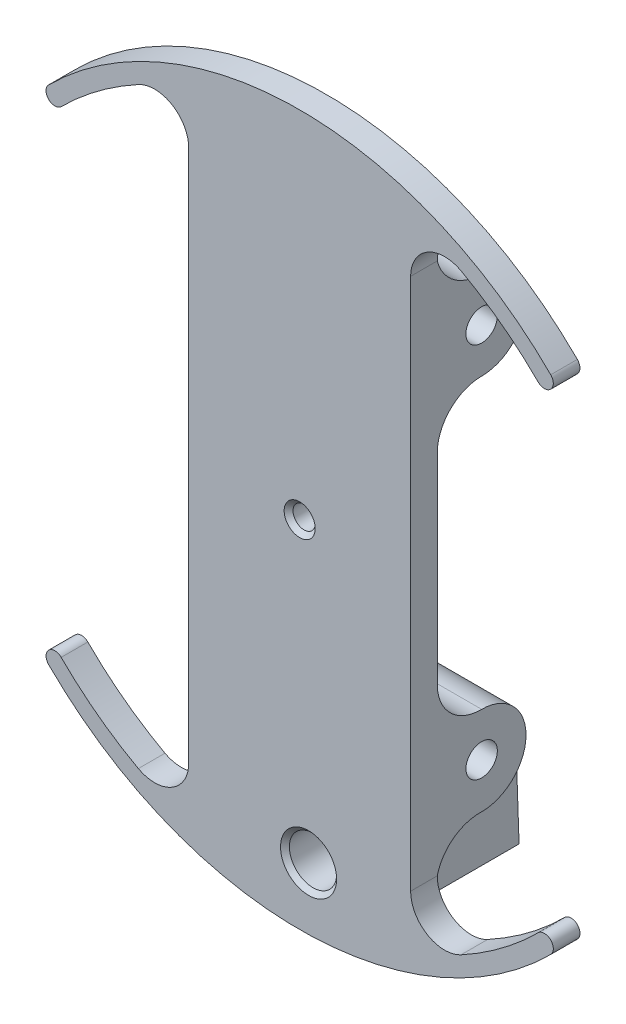
from build123d import *

# Parameters (mm, degrees)
MAIN_BODY_DEPTH                 = 3.81
BOSSES_FOR_SCREWS_DEPTH         = 31.75
F_8_CLEARANCE_HOLE_FOR_SCREWS_D = 4.4958
SWITCH_HOLDER_BODY_REACH        = 65.711
SKETCH19_R                      = 3.3782
F_1_4_QR_PIN_HOLE_D             = 6.7564
F_1_4_QR_PIN_HOLE_CSINK_D       = 8.0264
F_1_4_QR_PIN_HOLE_CSINK_ANGLE   = 90
SKETCH25_R                      = 1.862
PLUNGER_HOLE_DEPTH              = 2.54
SKETCH33_W                      = 6.4
SKETCH33_H                      = 6.4
SWITCH_BODY_CLEARANCE_DEPTH     = 0.65024
F_2_CLEARANCE_HOLE1_D           = 2.4384
F_2_CLEARANCE_HOLE1_DEPTH       = 3.175
TAP_DRILL_FOR_2_56_TAP1_D       = 1.778
TAP_DRILL_FOR_2_56_TAP1_DEPTH   = 12.7


with BuildPart() as part:
    # Sketch3 → Main Body (new body)
    with BuildSketch(Plane.XY):
        with BuildLine():
            Line((-15.875, -38.1), (-15.875, 38.1))
            ThreePointArc((-15.875, 38.1), (-18.260491841, 42.291797068), (-23.082694008, 42.38179842))
            ThreePointArc((-23.082694008, 42.38179842), (-28.900226452, 38.649767283), (-34.12497326, 34.12497326))
            ThreePointArc((-34.12497326, 34.12497326), (-35.921024484, 34.12497326), (-35.921024484, 35.921024484))
            ThreePointArc((-35.921024484, 35.921024484), (0, 50.8), (35.921024484, 35.921024484))
            ThreePointArc((35.921024484, 35.921024484), (35.921024484, 34.12497326), (34.12497326, 34.12497326))
            ThreePointArc((34.12497326, 34.12497326), (28.900226452, 38.649767283), (23.082694008, 42.38179842))
            ThreePointArc((23.082694008, 42.38179842), (18.260491841, 42.291797068), (15.875, 38.1))
            Line((15.875, 38.1), (15.875, -38.1))
            ThreePointArc((15.875, -38.1), (18.260491841, -42.291797068), (23.082694008, -42.38179842))
            ThreePointArc((23.082694008, -42.38179842), (28.900226452, -38.649767283), (34.12497326, -34.12497326))
            ThreePointArc((34.12497326, -34.12497326), (35.921024484, -34.12497326), (35.921024484, -35.921024484))
            ThreePointArc((35.921024484, -35.921024484), (0, -50.8), (-35.921024484, -35.921024484))
            ThreePointArc((-35.921024484, -35.921024484), (-35.921024484, -34.12497326), (-34.12497326, -34.12497326))
            ThreePointArc((-34.12497326, -34.12497326), (-28.900226452, -38.649767283), (-23.082694008, -42.38179842))
            ThreePointArc((-23.082694008, -42.38179842), (-18.260491841, -42.291797068), (-15.875, -38.1))
        make_face()
    extrude(amount=MAIN_BODY_DEPTH)

    # Sketch5 → Bosses for screws (add)
    with BuildSketch(Plane(origin=(15.875, 0, 0), x_dir=(0, 0, -1), z_dir=(1, 0, 0))):
        with BuildLine():
            Line((0, 38.1), (0, 26.99385))
            Line((0, 26.99385), (0, 14.29385))
            ThreePointArc((0, 14.29385), (1.86498297, 18.77886703), (6.35, 20.64385))
            ThreePointArc((6.35, 20.64385), (12.699998494, 26.998224058), (6.341251887, 33.343843974))
            ThreePointArc((6.341251887, 33.343843974), (2.338844583, 34.612930799), (0, 38.1))
        make_face()
        with BuildLine():
            ThreePointArc((6.261703048, -20.644463916), (1.864650947, -18.840779739), (0, -14.469233029))
            Line((0, -14.469233029), (0, -26.99385))
            Line((0, -26.99385), (0, -38.1))
            ThreePointArc((0, -38.1), (2.217611083, -34.670801888), (6.077775616, -33.338012189))
            ThreePointArc((6.077775616, -33.338012189), (6.213919542, -33.33945129), (6.35, -33.34385))
            ThreePointArc((6.35, -33.34385), (12.7, -26.99385), (6.35, -20.64385))
            ThreePointArc((6.35, -20.64385), (6.305852606, -20.644312569), (6.261703048, -20.644463916))
        make_face()
    extrude(amount=-BOSSES_FOR_SCREWS_DEPTH)

    # #8 Clearance Hole for screws (through all)
    with Locations(Plane(origin=(15.875, 0, 0), x_dir=(0, 0, -1), z_dir=(1, 0, 0))):
        with Locations((6.35, 26.99385), (6.35, -26.893399733)):
            Hole(F_8_CLEARANCE_HOLE_FOR_SCREWS_D / 2)

    # Sketch10 → 1/8 (0.125) Diameter let down hole (revolve, cut)
    with BuildSketch(Plane.YZ):
        Polygon((0, 0), (0, 3.81), (2.2225, 3.81), (1.5875, 3.175), (1.5875, 0.635), (2.2225, 0), align=None)
    revolve(axis=Axis((0, 0, -6.35), (0, 0, 1)), mode=Mode.SUBTRACT)

    # Switch holder body: up to this plane
    switch_holder_body_end = Plane(origin=(-3.297630422, -38.686979812, -19.719207275), z_dir=(0.008390733100517729, 0.03489949670250099, -0.9993556027400597))
    # Sketch19 → Switch holder body (add, up to the surface)
    with BuildSketch(Plane(origin=(0, 0, 0), x_dir=(-1, 0, 0), z_dir=(0, 0, -1)), mode=Mode.PRIVATE) as switch_holder_body_sk1:
        Polygon((12.7, -38.735), (2.921, -38.735), (2.921, -45.085), (12.7, -45.085), (12.7, -48.26), (-7.62, -48.26), (-7.62, -35.56), (12.7, -35.56), align=None)
        with Locations(Location((-1.27, -41.91, 0), (0, 0, 103.518789087))):
            Circle(SKETCH19_R, mode=Mode.SUBTRACT)
    switch_holder_body_tool1 = split(extrude(switch_holder_body_sk1.sketch, amount=SWITCH_HOLDER_BODY_REACH, mode=Mode.PRIVATE), bisect_by=switch_holder_body_end, keep=Keep.BOTH, mode=Mode.PRIVATE)
    add(switch_holder_body_tool1.solids().sort_by_distance((-7.8105, -38.495377, 0))[0])

    # 1/4 QR pin hole (through all)
    with Locations(Plane.XY.offset(3.81)):
        with Locations((1.27, -41.91)):
            CounterSinkHole(F_1_4_QR_PIN_HOLE_D / 2, F_1_4_QR_PIN_HOLE_CSINK_D / 2, counter_sink_angle=F_1_4_QR_PIN_HOLE_CSINK_ANGLE)

    # Sketch25 → plunger hole (cut)
    with BuildSketch(Plane.ZY.offset(2.921)):
        with Locations(Location((-7.285, -41.935, 0), (0, 0, 270))):
            Circle(SKETCH25_R)
    extrude(amount=-PLUNGER_HOLE_DEPTH, mode=Mode.SUBTRACT)

    # Sketch33 → switch body clearance (cut)
    with BuildSketch(Plane.ZY.offset(2.921)):
        with Locations((-7.285, -41.935)):
            Rectangle(SKETCH33_W, SKETCH33_H)
    extrude(amount=-SWITCH_BODY_CLEARANCE_DEPTH, mode=Mode.SUBTRACT)

    # #2 Clearance Hole1
    with Locations(Plane(origin=(0, -48.26, 0), x_dir=(-1, 0, 0), z_dir=(0, -1, 0))):
        with Locations((9.571, 14.7), (9.571, 5.2)):
            Hole(F_2_CLEARANCE_HOLE1_D / 2, depth=F_2_CLEARANCE_HOLE1_DEPTH)

    # Tap Drill for #2-56 Tap1
    with Locations(Plane(origin=(0, -48.26, 0), x_dir=(-1, 0, 0), z_dir=(0, -1, 0))):
        with Locations((9.571, 14.7), (9.571, 5.2)):
            Hole(TAP_DRILL_FOR_2_56_TAP1_D / 2, depth=TAP_DRILL_FOR_2_56_TAP1_DEPTH)


solid = part.part
